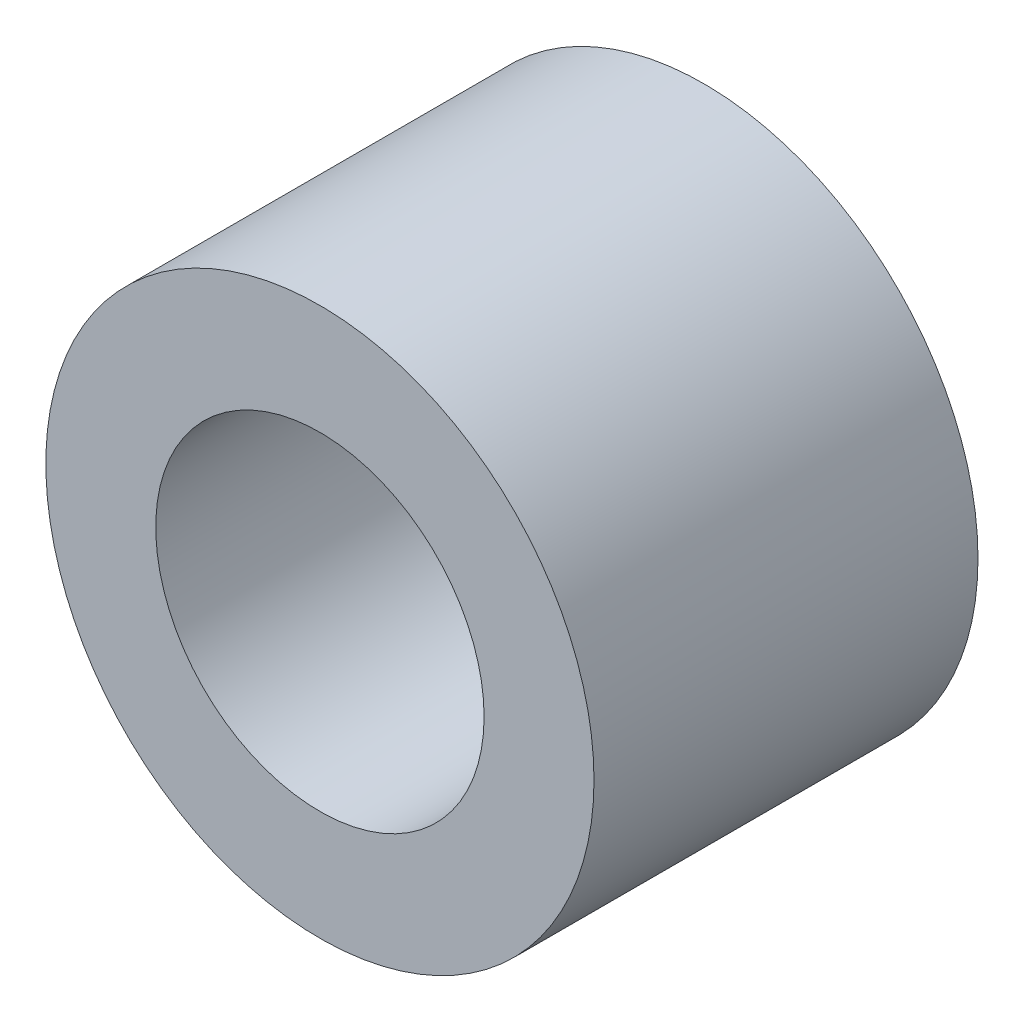
from build123d import *

# Parameters (mm, degrees)
SKETCH1_R           = 2.6289
SKETCH1_R_2         = 1.5748
BOSS_EXTRUDE1_DEPTH = 3.683


with BuildPart() as part:
    # Sketch1 → Boss-Extrude1 (new body)
    with BuildSketch(Plane.XY):
        Circle(SKETCH1_R)
        Circle(SKETCH1_R_2, mode=Mode.SUBTRACT)
    extrude(amount=BOSS_EXTRUDE1_DEPTH)


solid = part.part
